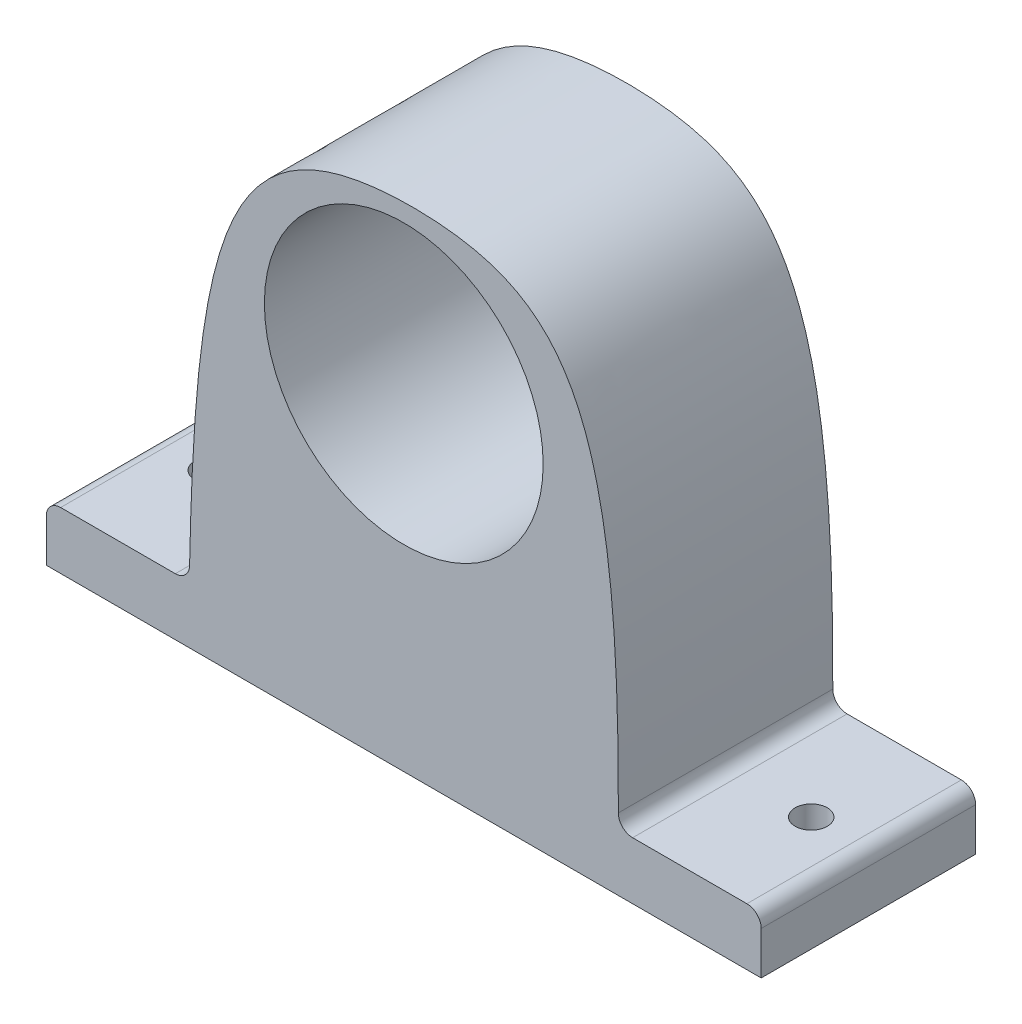
from build123d import *

# Parameters (mm, degrees)
SKETCH1_W           = 100
SKETCH1_H           = 30
BOSS_EXTRUDE1_DEPTH = 8
BOSS_EXTRUDE2_DEPTH = 30
SKETCH3_R           = 19.5
CUT_EXTRUDE1_DEPTH  = 31.0000001
SKETCH4_R           = 2.25
CUT_EXTRUDE2_DEPTH  = 9.0000001
FILLET1_R           = 2


with BuildPart() as part:
    # Sketch1 → Boss-Extrude1 (new body)
    with BuildSketch(Plane(origin=(0, 0, 0), x_dir=(1, 0, 0), z_dir=(0, 1, 0))):
        Rectangle(SKETCH1_W, SKETCH1_H)
    extrude(amount=BOSS_EXTRUDE1_DEPTH)

    # Sketch2 → Boss-Extrude2 (add)
    with BuildSketch(Plane.XY.offset(15)):
        with BuildLine():
            Line((50, 8), (30, 8))
            add(Edge.make_bspline(
                [(-30, 8), (-29.294848192, 47.159550373), (-25.059451985, 68.493847629), (21.924040743, 69.715154385), (30.440802585, 55.381053133), (30, 8)],
                knots=[0, 0, 0, 0, 0.475247095, 0.575247095, 1, 1, 1, 1], degree=3))
            Line((-30, 8), (-50, 8))
            Line((-50, 8), (-50, 0))
            Line((-50, 0), (50, 0))
            Line((50, 0), (50, 8))
        make_face()
    extrude(amount=-BOSS_EXTRUDE2_DEPTH)

    # Sketch3 → Cut-Extrude1 (cut, through all)
    with BuildSketch(Plane.XY.offset(15)):
        with Locations((0, 47)):
            Circle(SKETCH3_R)
    extrude(amount=-CUT_EXTRUDE1_DEPTH, mode=Mode.SUBTRACT)

    # Sketch4 → Cut-Extrude2 (cut, through all)
    with BuildSketch(Plane(origin=(0, 8, 0), x_dir=(1, 0, 0), z_dir=(0, 1, 0))):
        with Locations((-42, 0)):
            Circle(SKETCH4_R)
        with Locations((42, 0)):
            Circle(SKETCH4_R)
    extrude(amount=-CUT_EXTRUDE2_DEPTH, mode=Mode.SUBTRACT)

    # Fillet1
    fillet1_edges = [part.edges().sort_by_distance(p)[0] for p in [
        (-30, 8, 0),
        (30, 8, 0),
        (50, 8, 0),
        (-50, 8, 0),
    ]]
    fillet(fillet1_edges, radius=FILLET1_R)


solid = part.part
